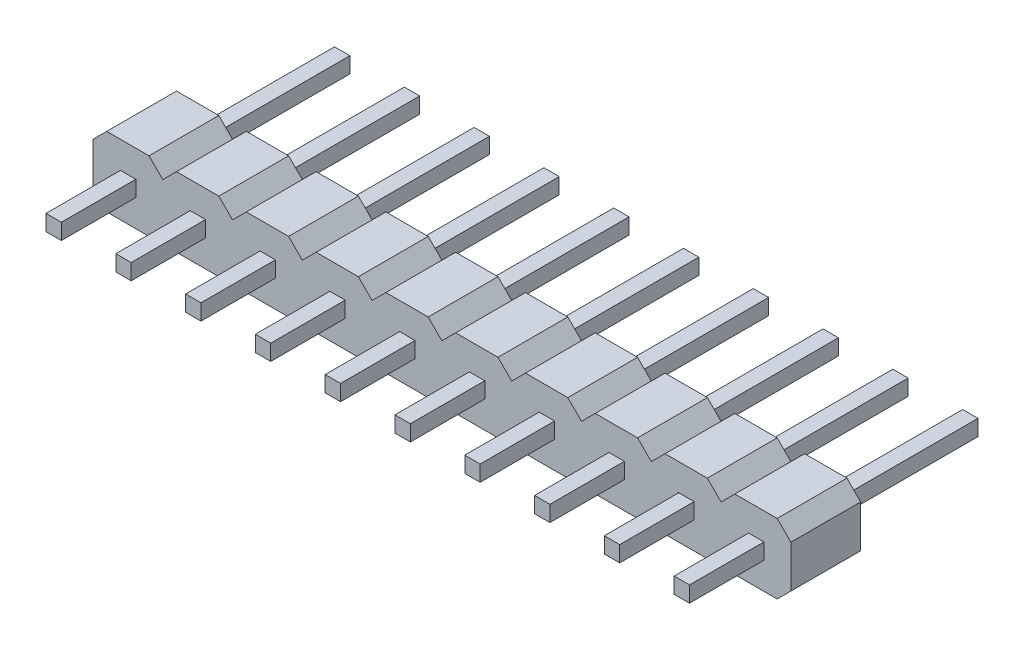
from build123d import *

# Parameters (mm, degrees)
SKETCH1_W                = 0.58
SKETCH1_H                = 0.58
BOSS_EXTRUDE1_DEPTH      = 2.54
BOSS_EXTRUDE2_DEPTH      = 5.25
BOSS_EXTRUDE2_DEPTH_BACK = 5.25
SKETCH2_W                = 0.5591264
SKETCH2_H                = 0.575944702


with BuildPart() as part:
    # Sketch1 → Boss-Extrude1 (new body)
    with BuildSketch(Plane.XY):
        Polygon((-37.946397324, 14.279123168), (-37.446397324, 14.779123168), (-35.906397324, 14.779123168), (-35.406397324, 14.279123168), (-34.906397324, 14.779123168), (-33.366397324, 14.779123168), (-32.866397324, 14.279123168), (-32.366397324, 14.779123168), (-30.826397324, 14.779123168), (-30.326397324, 14.279123168), (-29.826397324, 14.779123168), (-28.286397324, 14.779123168), (-27.786397324, 14.279123168), (-27.286397324, 14.779123168), (-25.746397324, 14.779123168), (-25.246397324, 14.279123168), (-24.746397324, 14.779123168), (-23.206397324, 14.779123168), (-22.706397324, 14.279123168), (-22.206397324, 14.779123168), (-20.666397324, 14.779123168), (-20.166397324, 14.279123168), (-19.666397324, 14.779123168), (-18.126397324, 14.779123168), (-17.626397324, 14.279123168), (-17.126397324, 14.779123168), (-15.586397324, 14.779123168), (-15.086397324, 14.279123168), (-14.586397324, 14.779123168), (-13.046397324, 14.779123168), (-12.546397324, 14.279123168), (-12.546397324, 12.739123168), (-13.046397324, 12.239123168), (-14.586397324, 12.239123168), (-15.086397324, 12.739123168), (-15.586397324, 12.239123168), (-17.126397324, 12.239123168), (-17.626397324, 12.739123168), (-18.126397324, 12.239123168), (-19.666397324, 12.239123168), (-20.166397324, 12.739123168), (-20.666397324, 12.239123168), (-22.206397324, 12.239123168), (-22.706397324, 12.739123168), (-23.206397324, 12.239123168), (-24.746397324, 12.239123168), (-25.246397324, 12.739123168), (-25.746397324, 12.239123168), (-27.286397324, 12.239123168), (-27.786397324, 12.739123168), (-28.286397324, 12.239123168), (-29.826397324, 12.239123168), (-30.326397324, 12.739123168), (-30.826397324, 12.239123168), (-32.366397324, 12.239123168), (-32.866397324, 12.739123168), (-33.366397324, 12.239123168), (-34.906397324, 12.239123168), (-35.406397324, 12.739123168), (-35.906397324, 12.239123168), (-37.446397324, 12.239123168), (-37.946397324, 12.739123168), align=None)
        with Locations((-16.356397324, 13.509123168)):
            Rectangle(SKETCH1_W, SKETCH1_H, mode=Mode.SUBTRACT)
        with Locations((-13.816397324, 13.509123168)):
            Rectangle(SKETCH1_W, SKETCH1_H, mode=Mode.SUBTRACT)
        with Locations((-18.896397324, 13.509123168)):
            Rectangle(SKETCH1_W, SKETCH1_H, mode=Mode.SUBTRACT)
        with Locations((-21.436397324, 13.509123168)):
            Rectangle(SKETCH1_W, SKETCH1_H, mode=Mode.SUBTRACT)
        with Locations((-23.976397324, 13.509123168)):
            Rectangle(SKETCH1_W, SKETCH1_H, mode=Mode.SUBTRACT)
        with Locations((-26.516397324, 13.509123168)):
            Rectangle(SKETCH1_W, SKETCH1_H, mode=Mode.SUBTRACT)
        with Locations((-29.056397324, 13.509123168)):
            Rectangle(SKETCH1_W, SKETCH1_H, mode=Mode.SUBTRACT)
        with Locations((-31.596397324, 13.509123168)):
            Rectangle(SKETCH1_W, SKETCH1_H, mode=Mode.SUBTRACT)
        with Locations((-34.136397324, 13.509123168)):
            Rectangle(SKETCH1_W, SKETCH1_H, mode=Mode.SUBTRACT)
        with Locations((-36.676397324, 13.509123168)):
            Rectangle(SKETCH1_W, SKETCH1_H, mode=Mode.SUBTRACT)
    extrude(amount=BOSS_EXTRUDE1_DEPTH)

    # Sketch2 → Boss-Extrude2 (add, two sides: drawn at the far end of the back side and taken through both)
    with BuildSketch(Plane.XY.offset(-BOSS_EXTRUDE2_DEPTH_BACK)):
        with Locations((-16.345960524, 13.511150817)):
            Rectangle(SKETCH2_W, SKETCH2_H)
        with Locations((-13.805960524, 13.511150817)):
            Rectangle(SKETCH2_W, SKETCH2_H)
        with Locations((-18.885960524, 13.511150817)):
            Rectangle(SKETCH2_W, SKETCH2_H)
        with Locations((-21.425960524, 13.511150817)):
            Rectangle(SKETCH2_W, SKETCH2_H)
        with Locations((-23.965960524, 13.511150817)):
            Rectangle(SKETCH2_W, SKETCH2_H)
        with Locations((-26.505960524, 13.511150817)):
            Rectangle(SKETCH2_W, SKETCH2_H)
        with Locations((-29.045960524, 13.511150817)):
            Rectangle(SKETCH2_W, SKETCH2_H)
        with Locations((-31.585960524, 13.511150817)):
            Rectangle(SKETCH2_W, SKETCH2_H)
        with Locations((-34.125960524, 13.511150817)):
            Rectangle(SKETCH2_W, SKETCH2_H)
        with Locations((-36.665960524, 13.511150817)):
            Rectangle(SKETCH2_W, SKETCH2_H)
    extrude(amount=BOSS_EXTRUDE2_DEPTH + BOSS_EXTRUDE2_DEPTH_BACK)


solid = part.part
